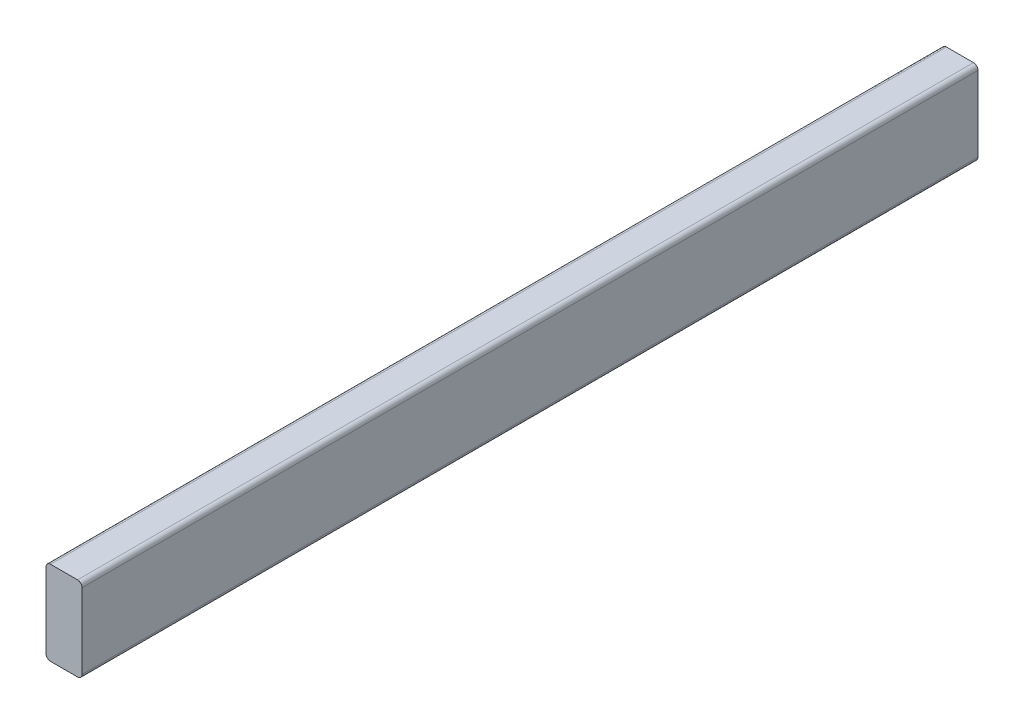
from build123d import *

# Parameters (mm, degrees)
SKETCH1_W           = 38.1
SKETCH1_H           = 88.9
BOSS_EXTRUDE1_DEPTH = 946.658829
FILLET1_R           = 4.7625


with BuildPart() as part:
    # Sketch1 → Boss-Extrude1 (new body)
    with BuildSketch(Plane.XY):
        with Locations((-800.780594651, 44.45)):
            Rectangle(SKETCH1_W, SKETCH1_H)
    extrude(amount=-BOSS_EXTRUDE1_DEPTH)

    # Fillet1
    fillet1_edges = [part.edges().sort_by_distance(p)[0] for p in [
        (-781.730594651, 88.9, -473.3294145),
        (-819.830594651, 88.9, -473.3294145),
        (-819.830594651, 0, -473.3294145),
        (-781.730594651, 0, -473.3294145),
    ]]
    fillet(fillet1_edges, radius=FILLET1_R)


solid = part.part
